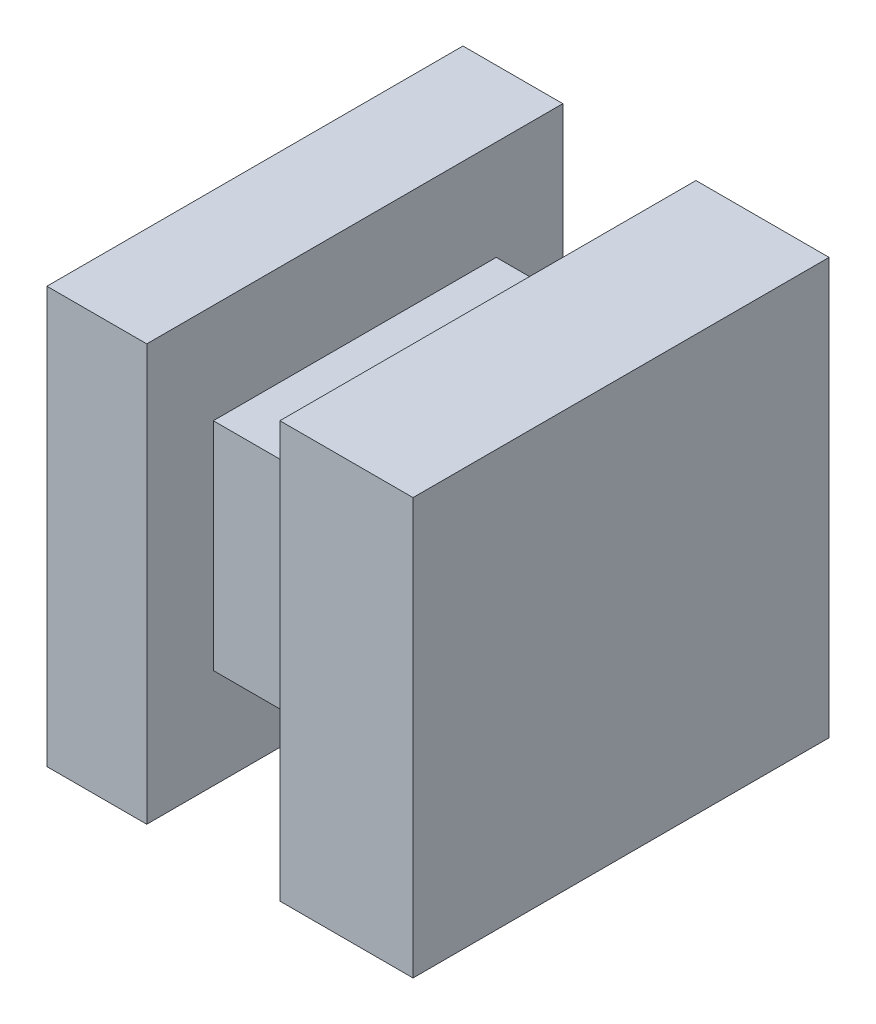
from build123d import *

# Parameters (mm, degrees)
BOSS_EXTRUDE2_DEPTH      = 12.5
SKETCH7_W                = 4
SKETCH7_H                = 2
CUT_EXTRUDE10_DEPTH      = 26
CUT_EXTRUDE11_DEPTH      = 4
CUT_EXTRUDE11_DEPTH_BACK = 10.5


with BuildPart() as part:
    # Sketch1 → Boss-Extrude2 (new body)
    with BuildSketch(Plane.XY):
        Polygon((-90.614577373, 45.459408198), (-87.614577373, 45.459408198), (-87.614577373, 42.459408198), (-83.614577373, 42.459408198), (-83.614577373, 45.459408198), (-79.614577373, 45.459408198), (-79.614577373, 32.959408198), (-83.614577373, 32.959408198), (-83.614577373, 35.959408198), (-87.614577373, 35.959408198), (-87.614577373, 32.959408198), (-90.614577373, 32.959408198), align=None)
    extrude(amount=BOSS_EXTRUDE2_DEPTH)

    # Sketch7 → Cut-Extrude10 (cut)
    with BuildSketch(Plane(origin=(0, 42.459408198, 0), x_dir=(1, 0, 0), z_dir=(0, 1, 0))):
        with Locations((-85.614577373, -11.5)):
            Rectangle(SKETCH7_W, SKETCH7_H)
    extrude(amount=-CUT_EXTRUDE10_DEPTH, mode=Mode.SUBTRACT)

    # Sketch8 → Cut-Extrude11 (cut, two sides)
    with BuildSketch(Plane(origin=(0, 42.459408198, 0), x_dir=(1, 0, 0), z_dir=(0, 1, 0))) as cut_extrude11_sk:
        Polygon((-87.614577373, 39.681644159), (-87.614577373, 0), (-87.614577373, -2), (-83.614577373, -2), (-83.614577373, 0), (-83.614577373, 39.681644159), (-83.614577373, 119.044932478), (-87.614577373, 119.044932478), align=None)
    extrude(amount=CUT_EXTRUDE11_DEPTH, mode=Mode.SUBTRACT)
    extrude(cut_extrude11_sk.sketch, amount=-CUT_EXTRUDE11_DEPTH_BACK, mode=Mode.SUBTRACT)


solid = part.part
